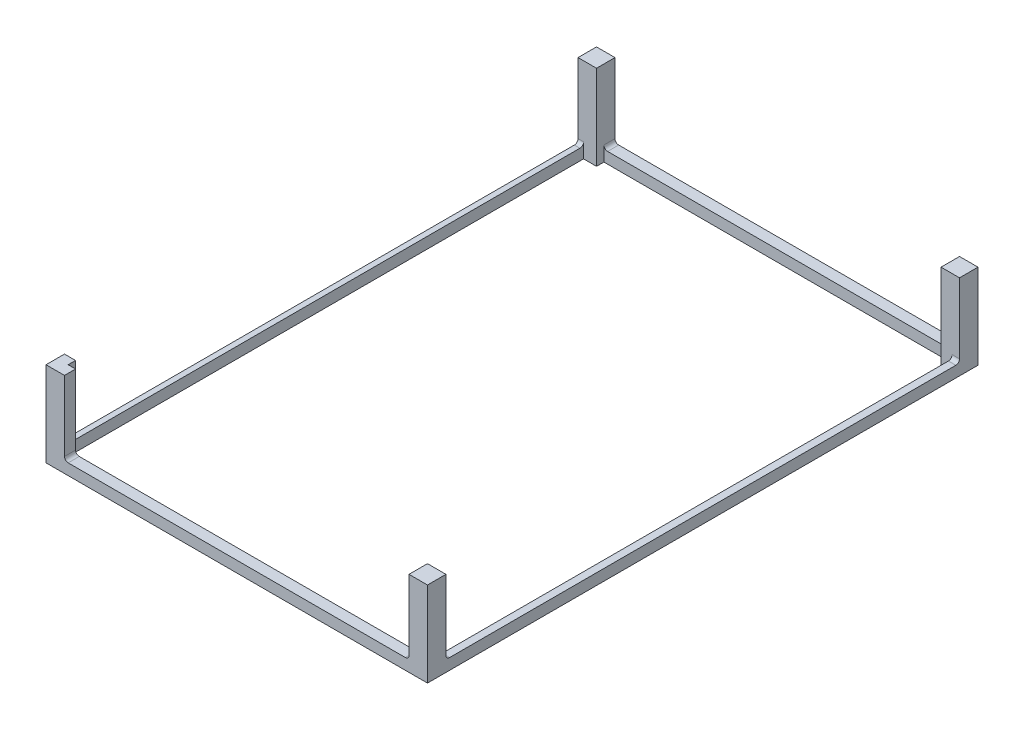
from build123d import *

# Parameters (mm, degrees)
BOSS_EXTRUDE1_DEPTH = 3
SKETCH2_W           = 5
SKETCH2_H           = 5
BOSS_EXTRUDE2_DEPTH = 20
FILLET1_R           = 1


with BuildPart() as part:
    # Sketch1 → Boss-Extrude1 (new body)
    with BuildSketch(Plane(origin=(0, 0, 0), x_dir=(1, 0, 0), z_dir=(0, 1, 0))):
        Polygon((0, 0), (0, 149), (5, 149), (103.25, 149), (103.25, 0), align=None)
        Polygon((98.25, 146), (5, 146), (5, 144), (1.5, 144), (1.5, 5), (3, 5), (3, 3), (5, 3), (98.25, 3), (98.25, 5), (101.25, 5), (101.25, 144), (98.25, 144), align=None, mode=Mode.SUBTRACT)
    extrude(amount=BOSS_EXTRUDE1_DEPTH)

    # Sketch2 → Boss-Extrude2 (add)
    with BuildSketch(Plane(origin=(0, 3, 0), x_dir=(1, 0, 0), z_dir=(0, 1, 0))):
        Polygon((0, 0), (5, 0), (5, 3), (3, 3), (3, 5), (0, 5), align=None)
        with Locations((100.75, 146.5)):
            Rectangle(SKETCH2_W, SKETCH2_H)
        with Locations((2.5, 146.5)):
            Rectangle(SKETCH2_W, SKETCH2_H)
        with Locations((100.75, 2.5)):
            Rectangle(SKETCH2_W, SKETCH2_H)
    extrude(amount=BOSS_EXTRUDE2_DEPTH)

    # Fillet1
    fillet1_edges = [part.edges().sort_by_distance(p)[0] for p in [
        (0.75, 3, -5),
        (102.25, 3, -144),
        (98.25, 3, -147.5),
        (0.75, 3, -144),
        (5, 3, -147.5),
        (98.25, 3, -1.5),
        (102.25, 3, -5),
        (5, 3, -1.5),
    ]]
    fillet(fillet1_edges, radius=FILLET1_R)


solid = part.part
